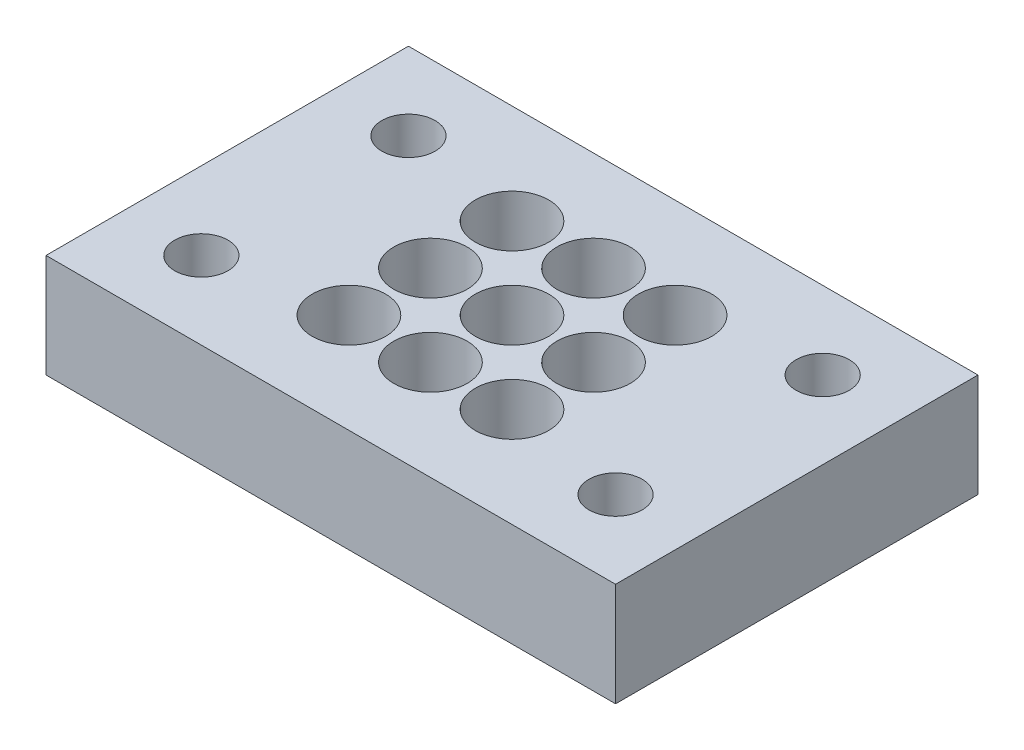
from build123d import *

# Parameters (mm, degrees)
SKETCH1_W           = 69.85
SKETCH1_H           = 44.45
SKETCH1_R           = 4.5
SKETCH1_R_2         = 3.2639
BOSS_EXTRUDE1_DEPTH = 12.7


with BuildPart() as part:
    # Sketch1 → Boss-Extrude1 (new body)
    with BuildSketch(Plane(origin=(0, 0, 0), x_dir=(1, 0, 0), z_dir=(0, 1, 0))):
        with Locations((34.925, 22.225)):
            Rectangle(SKETCH1_W, SKETCH1_H)
        with Locations((24.925, 12.225)):
            Circle(SKETCH1_R, mode=Mode.SUBTRACT)
        with Locations((34.925, 12.225)):
            Circle(SKETCH1_R, mode=Mode.SUBTRACT)
        with Locations((44.925, 12.225)):
            Circle(SKETCH1_R, mode=Mode.SUBTRACT)
        with Locations((24.925, 32.225)):
            Circle(SKETCH1_R, mode=Mode.SUBTRACT)
        with Locations((24.925, 22.225)):
            Circle(SKETCH1_R, mode=Mode.SUBTRACT)
        with Locations((34.925, 32.225)):
            Circle(SKETCH1_R, mode=Mode.SUBTRACT)
        with Locations((44.925, 32.225)):
            Circle(SKETCH1_R, mode=Mode.SUBTRACT)
        with Locations((44.925, 22.225)):
            Circle(SKETCH1_R, mode=Mode.SUBTRACT)
        with Locations((34.925, 22.225)):
            Circle(SKETCH1_R, mode=Mode.SUBTRACT)
        with Locations((60.325, 9.525)):
            Circle(SKETCH1_R_2, mode=Mode.SUBTRACT)
        with Locations((9.525, 9.525)):
            Circle(SKETCH1_R_2, mode=Mode.SUBTRACT)
        with Locations((60.325, 34.925)):
            Circle(SKETCH1_R_2, mode=Mode.SUBTRACT)
        with Locations((9.525, 34.925)):
            Circle(SKETCH1_R_2, mode=Mode.SUBTRACT)
    extrude(amount=BOSS_EXTRUDE1_DEPTH)


solid = part.part
